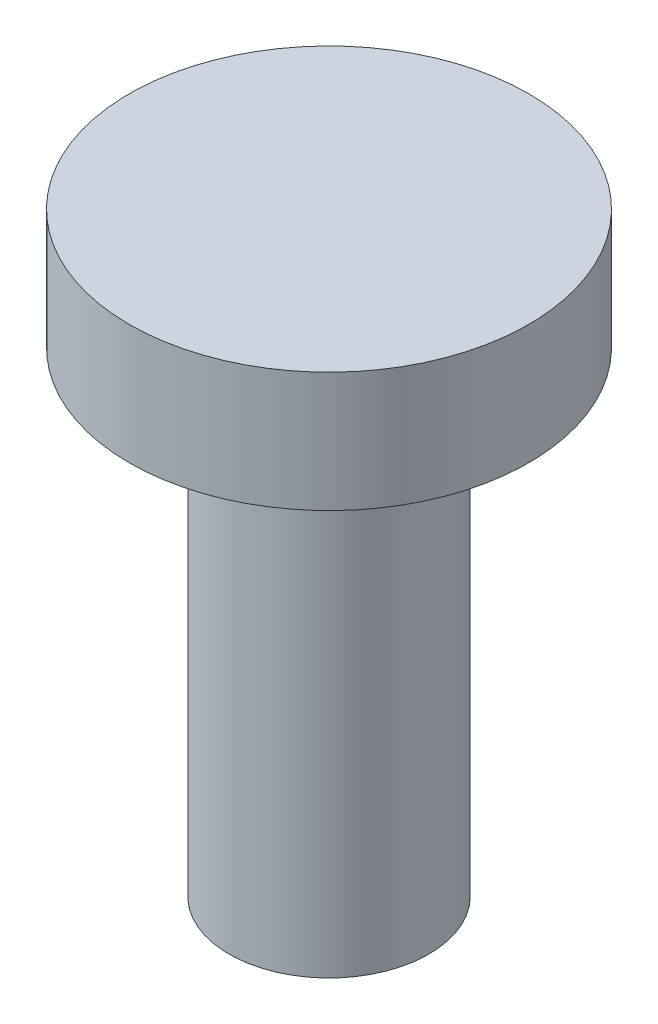
from build123d import *

# Parameters (mm, degrees)
SKETCH1_R           = 5
BOSS_EXTRUDE1_DEPTH = 3
SKETCH2_R           = 2.5
BOSS_EXTRUDE2_DEPTH = 11.8999


with BuildPart() as part:
    # Sketch1 → Boss-Extrude1 (new body)
    with BuildSketch(Plane(origin=(0, 0, 0), x_dir=(1, 0, 0), z_dir=(0, 1, 0))):
        Circle(SKETCH1_R)
    extrude(amount=BOSS_EXTRUDE1_DEPTH)

    # Sketch2 → Boss-Extrude2 (add)
    with BuildSketch(Plane.XZ):
        Circle(SKETCH2_R)
    extrude(amount=BOSS_EXTRUDE2_DEPTH)


solid = part.part
